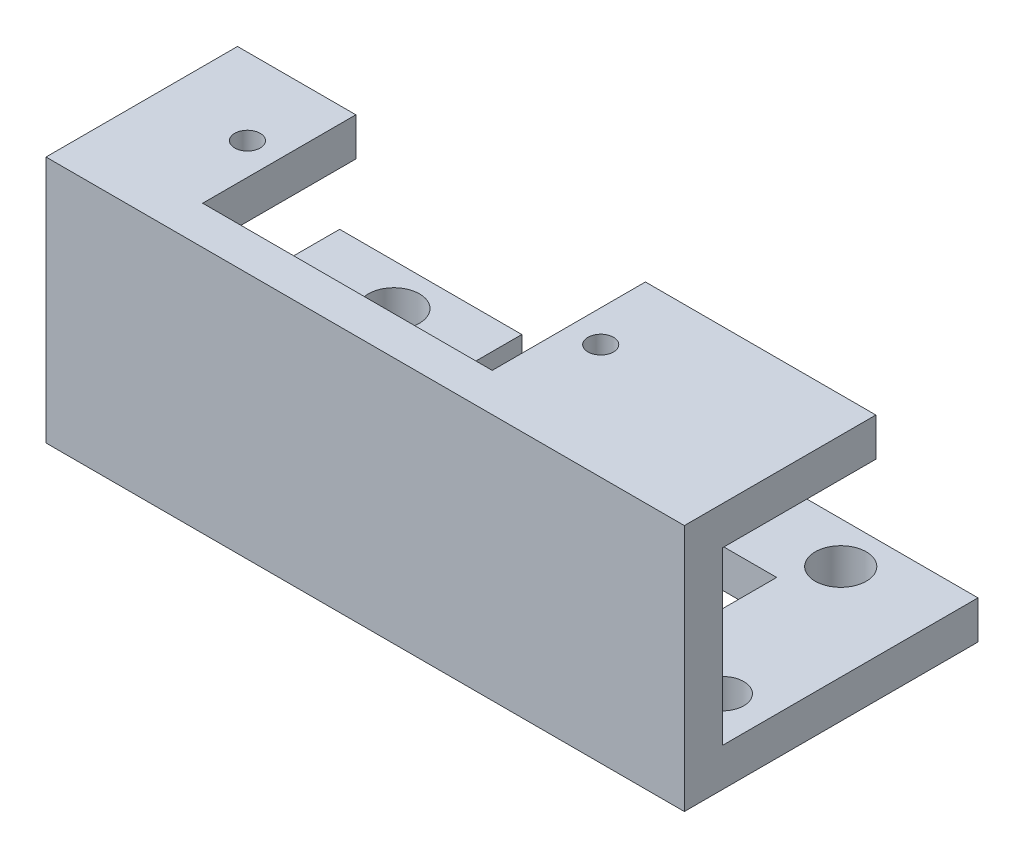
from build123d import *

# Parameters (mm, degrees)
SKETCH_1_W          = 50
SKETCH_1_H          = 19.4
EXTRUDE_1_DEPTH     = 3
SKETCH_2_W          = 18.05
SKETCH_2_H          = 3
SKETCH_2_W_2        = 9.27
EXTRUDE_3_DEPTH     = 12
SKETCH_5_R          = 1
CUT_EXTRUDE_1_DEPTH = 4
SKETCH_6_W          = 9.27
SKETCH_6_H          = 2.996679997
EXTRUDE_5_DEPTH     = 20
SKETCH_9_W          = 6.5
SKETCH_9_H          = 2.996679997
EXTRUDE_6_DEPTH     = 5
SKETCH_10_W         = 6.5
SKETCH_10_H         = 2.996679997
EXTRUDE_7_DEPTH     = 5
SKETCH_11_R         = 2
SKETCH_11_R_2       = 1.65
CUT_EXTRUDE_3_DEPTH = 5
SKETCH_12_R         = 2
SKETCH_12_R_2       = 1.65
CUT_EXTRUDE_4_DEPTH = 5


with BuildPart() as part:
    # 草图1 → 凸台-拉伸1 (new body)
    with BuildSketch(Plane.XY):
        with Locations((25, 9.7)):
            Rectangle(SKETCH_1_W, SKETCH_1_H)
    extrude(amount=EXTRUDE_1_DEPTH)

    # 草图2 → 凸台-拉伸3 (add)
    with BuildSketch(Plane(origin=(0, 0, 0), x_dir=(-1, 0, 0), z_dir=(0, 0, -1))):
        with Locations((-40.975, 17.9)):
            Rectangle(SKETCH_2_W, SKETCH_2_H)
        with Locations((-4.635, 17.9)):
            Rectangle(SKETCH_2_W_2, SKETCH_2_H)
    extrude(amount=EXTRUDE_3_DEPTH)

    # 草图5 → 切除-拉伸1 (cut)
    with BuildSketch(Plane(origin=(0, 19.4, 0), x_dir=(1, 0, 0), z_dir=(0, 1, 0))):
        with Locations((34.45, 6)):
            Circle(SKETCH_5_R)
        with Locations((6.78, 6)):
            Circle(SKETCH_5_R)
    extrude(amount=-CUT_EXTRUDE_1_DEPTH, mode=Mode.SUBTRACT)

    # 草图6 → 凸台-拉伸5 (add)
    with BuildSketch(Plane(origin=(0, 0, 0), x_dir=(-1, 0, 0), z_dir=(0, 0, -1))):
        with Locations((-45.365, 1.498339999)):
            Rectangle(SKETCH_6_W, SKETCH_6_H)
        with Locations((-4.635, 1.498339999)):
            Rectangle(SKETCH_6_W, SKETCH_6_H)
    extrude(amount=EXTRUDE_5_DEPTH)

    # 草图9 → 凸台-拉伸6 (add)
    with BuildSketch(Plane(origin=(9.27, 0, 0), x_dir=(0, 0, -1), z_dir=(1, 0, 0))):
        with Locations((16.75, 1.498339999)):
            Rectangle(SKETCH_9_W, SKETCH_9_H)
    extrude(amount=EXTRUDE_6_DEPTH)

    # 草图10 → 凸台-拉伸7 (add)
    with BuildSketch(Plane.ZY.offset(-40.73)):
        with Locations((-16.75, 1.498339999)):
            Rectangle(SKETCH_10_W, SKETCH_10_H)
    extrude(amount=EXTRUDE_7_DEPTH)

    # 草图11 → 切除-拉伸3 (cut)
    with BuildSketch(Plane(origin=(0, 2.996679997, 0), x_dir=(1, 0, 0), z_dir=(0, 1, 0))):
        with Locations((42.5, 16.75)):
            Circle(SKETCH_11_R)
        with Locations((46.5, 3.5)):
            Circle(SKETCH_11_R_2)
    extrude(amount=-CUT_EXTRUDE_3_DEPTH, mode=Mode.SUBTRACT)

    # 草图12 → 切除-拉伸4 (cut)
    with BuildSketch(Plane(origin=(0, 2.996679997, 0), x_dir=(1, 0, 0), z_dir=(0, 1, 0))):
        with Locations((7.5, 16.75)):
            Circle(SKETCH_12_R)
        with Locations((3.5, 3.5)):
            Circle(SKETCH_12_R_2)
    extrude(amount=-CUT_EXTRUDE_4_DEPTH, mode=Mode.SUBTRACT)


solid = part.part
